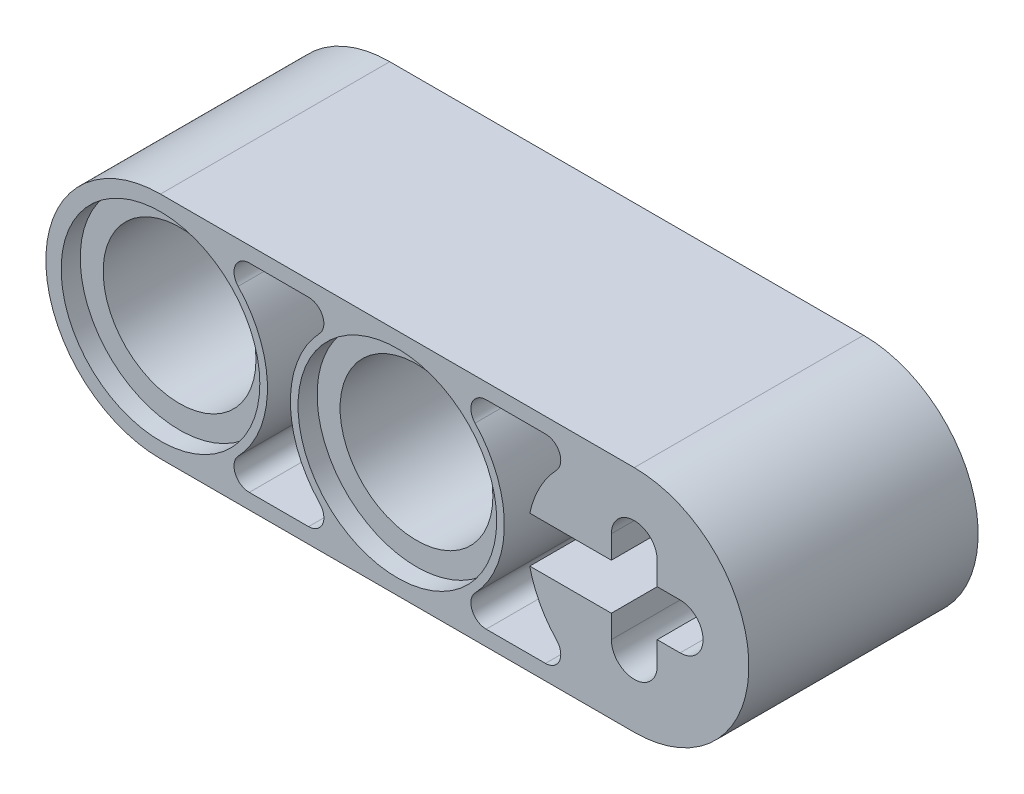
from build123d import *

# Parameters (mm, degrees)
SKETCH1_R           = 2.54
BOSS_EXTRUDE1_DEPTH = 3.81
SKETCH2_R           = 3.302
CUT_EXTRUDE3_DEPTH  = 0.635


with BuildPart() as part:
    # Sketch1 → Boss-Extrude1 (new body)
    with BuildSketch(Plane.XY):
        with BuildLine():
            ThreePointArc((7.874, -3.81), (11.684, 0), (7.874, 3.81))
            Line((7.874, 3.81), (-7.874, 3.81))
            ThreePointArc((-7.874, 3.81), (-11.684, 0), (-7.874, -3.81))
            Line((-7.874, -3.81), (7.874, -3.81))
        make_face()
        with BuildLine():
            ThreePointArc((-2.95121331, 3.302), (-2.484585514, 2.994804631), (-2.582311646, 2.44475))
            ThreePointArc((-2.582311646, 2.44475), (-3.556, 0), (-2.582311646, -2.44475))
            ThreePointArc((-2.582311646, -2.44475), (-2.484585514, -2.994804631), (-2.95121331, -3.302))
            Line((-2.95121331, -3.302), (-4.92278669, -3.302))
            ThreePointArc((-4.92278669, -3.302), (-5.389414486, -2.994804631), (-5.291688354, -2.44475))
            ThreePointArc((-5.291688354, -2.44475), (-4.318, 0), (-5.291688354, 2.44475))
            ThreePointArc((-5.291688354, 2.44475), (-5.389414486, 2.994804631), (-4.92278669, 3.302))
            Line((-4.92278669, 3.302), (-2.95121331, 3.302))
        make_face(mode=Mode.SUBTRACT)
        Circle(SKETCH1_R, mode=Mode.SUBTRACT)
        with BuildLine():
            Line((4.92278669, -3.302), (2.95121331, -3.302))
            ThreePointArc((2.95121331, -3.302), (2.484585514, -2.994804631), (2.582311646, -2.44475))
            ThreePointArc((2.582311646, -2.44475), (3.556, 0), (2.582311646, 2.44475))
            ThreePointArc((2.582311646, 2.44475), (2.484585514, 2.994804631), (2.95121331, 3.302))
            Line((2.95121331, 3.302), (4.92278669, 3.302))
            ThreePointArc((4.92278669, 3.302), (5.389414486, 2.994804631), (5.291688354, 2.44475))
            ThreePointArc((5.291688354, 2.44475), (4.731418896, 1.664127401), (4.40060224, 0.762))
            Line((4.40060224, 0.762), (7.112, 0.762))
            Line((7.112, 0.762), (7.112, 1.524))
            ThreePointArc((7.112, 1.524), (7.874, 2.286), (8.636, 1.524))
            Line((8.636, 1.524), (8.636, 0.762))
            Line((8.636, 0.762), (9.398, 0.762))
            ThreePointArc((9.398, 0.762), (10.16, 0), (9.398, -0.762))
            Line((9.398, -0.762), (8.636, -0.762))
            Line((8.636, -0.762), (8.636, -1.524))
            ThreePointArc((8.636, -1.524), (7.874, -2.286), (7.112, -1.524))
            Line((7.112, -1.524), (7.112, -0.762))
            Line((7.112, -0.762), (4.40060224, -0.762))
            ThreePointArc((4.40060224, -0.762), (4.731418896, -1.664127401), (5.291688354, -2.44475))
            ThreePointArc((5.291688354, -2.44475), (5.389414486, -2.994804631), (4.92278669, -3.302))
        make_face(mode=Mode.SUBTRACT)
        with Locations((-7.874, 0)):
            Circle(SKETCH1_R, mode=Mode.SUBTRACT)
    extrude(amount=BOSS_EXTRUDE1_DEPTH)

    # Sketch2 → Cut-Extrude3 (cut)
    with BuildSketch(Plane.XY):
        Circle(SKETCH2_R)
        with Locations((-7.874, 0)):
            Circle(SKETCH2_R)
    extrude(amount=CUT_EXTRUDE3_DEPTH, mode=Mode.SUBTRACT)

    # Mirror1: part across face


with BuildPart() as part_1:
    add(part.part)
    add(part.part.mirror(Plane(origin=(0.730328886, 0, 3.81), x_dir=(1, 0, 0), z_dir=(0, 0, 1))))


solid = part_1.part
